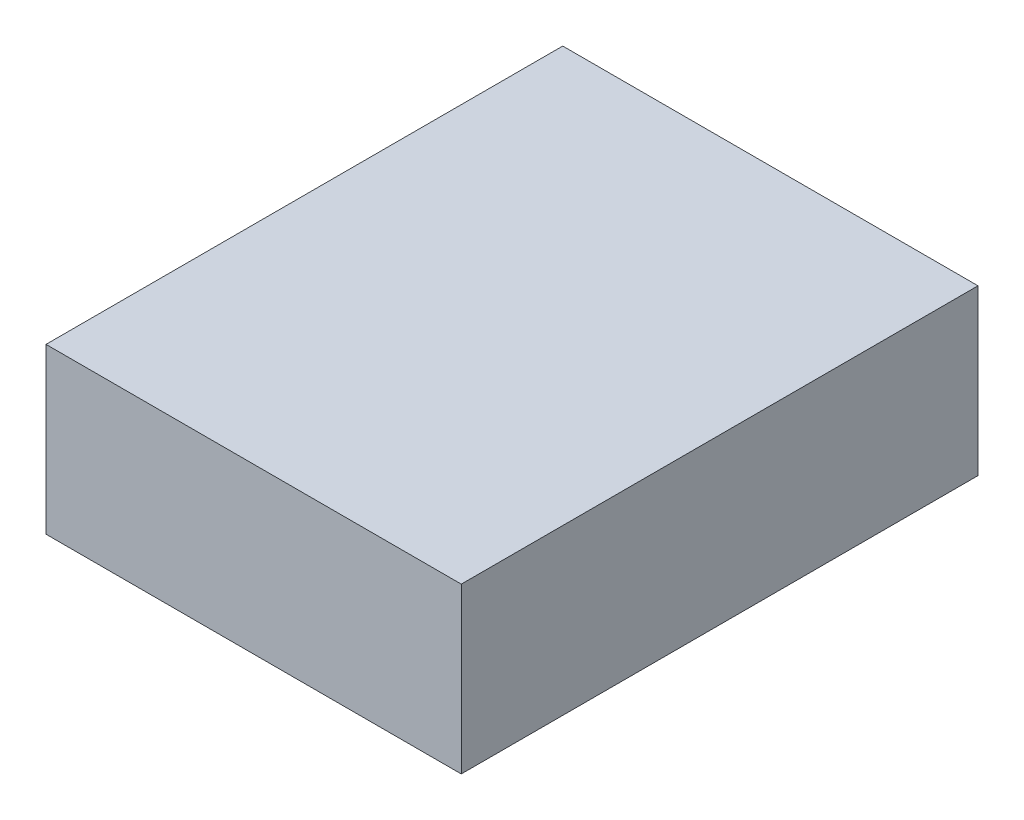
from build123d import *

# Parameters (mm, degrees)
SKETCH_1_W      = 442
SKETCH_1_H      = 550
EXTRUDE_1_DEPTH = 175


with BuildPart() as part:
    # Эскиз1 → Бобышка-Вытянуть1 (new body)
    with BuildSketch(Plane(origin=(0, 0, 0), x_dir=(1, 0, 0), z_dir=(0, 1, 0))):
        with Locations((221, 275)):
            Rectangle(SKETCH_1_W, SKETCH_1_H)
    extrude(amount=EXTRUDE_1_DEPTH)


solid = part.part
